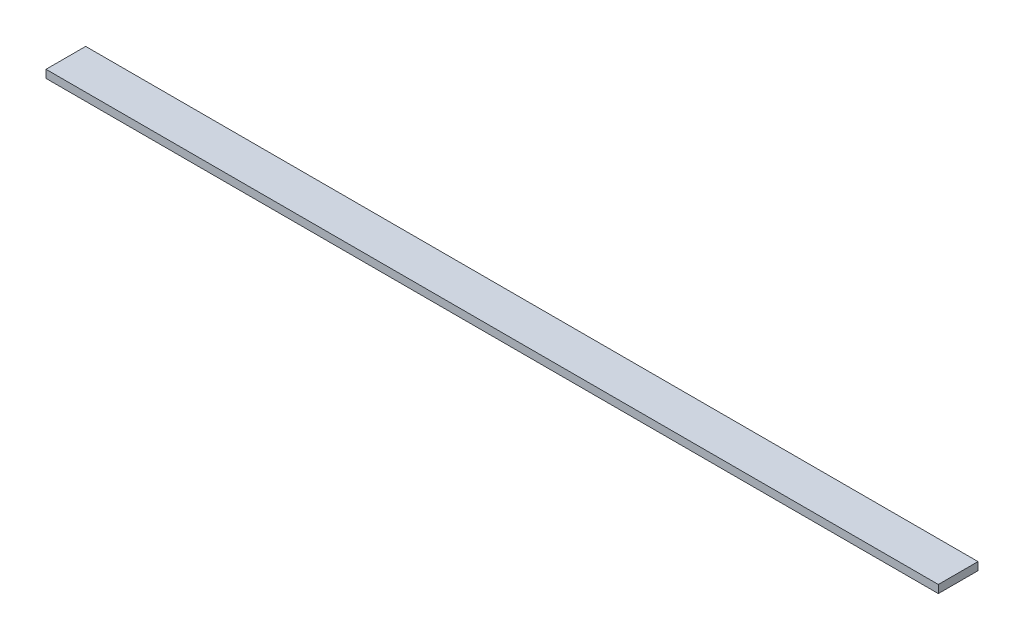
from build123d import *

# Parameters (mm, degrees)
SKETCH_1_W      = 20
SKETCH_1_H      = 4
EXTRUDE_1_DEPTH = 450


with BuildPart() as part:
    # Эскиз1 → Вытянуть-Тонкостенный1 (new body)
    with BuildSketch(Plane(origin=(0, 0, 0), x_dir=(0, 0, -1), z_dir=(1, 0, 0))):
        with Locations((10, -2)):
            Rectangle(SKETCH_1_W, SKETCH_1_H)
    extrude(amount=EXTRUDE_1_DEPTH)


solid = part.part
